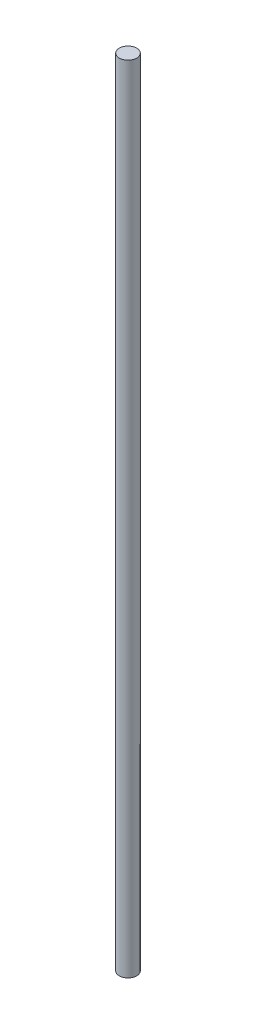
from build123d import *

# Parameters (mm, degrees)
SKETCH2_R           = 0.875
BOSS_EXTRUDE1_DEPTH = 80


with BuildPart() as part:
    # Sketch2 → Boss-Extrude1 (new body)
    with BuildSketch(Plane(origin=(0, 0, 0), x_dir=(1, 0, 0), z_dir=(0, 1, 0))):
        Circle(SKETCH2_R)
    extrude(amount=BOSS_EXTRUDE1_DEPTH)


solid = part.part
